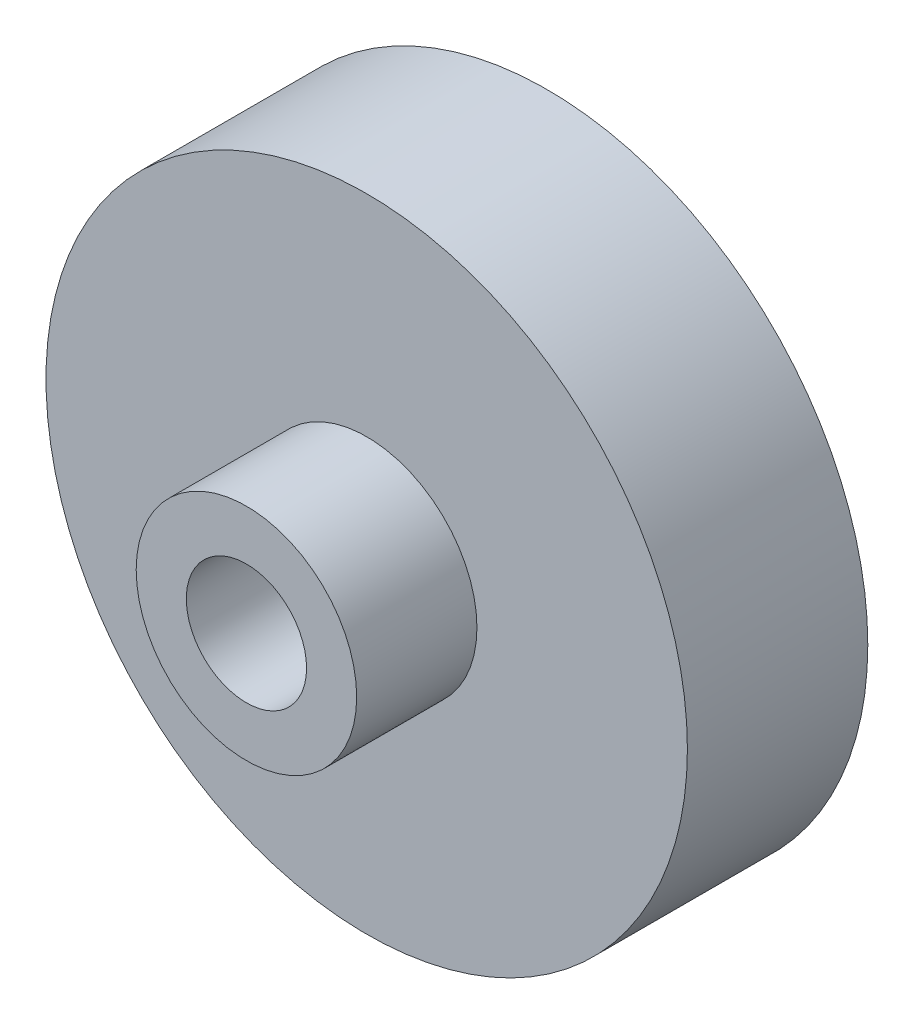
from build123d import *

# Parameters (mm, degrees)
SKETCH_1_R          = 16
EXTRUDE_1_DEPTH     = 9
SKETCH_2_R          = 6
EXTRUDE_2_DEPTH     = 0.5
SKETCH_3_R          = 16
EXTRUDE_3_DEPTH     = 3.25
SKETCH_4_R          = 5.5
EXTRUDE_4_DEPTH     = 2.25
SKETCH_5_R          = 3
CUT_EXTRUDE_1_DEPTH = 26.25
SKETCH_6_R          = 8
SKETCH_6_R_2        = 5.5
CUT_EXTRUDE_2_DEPTH = 2.25
SKETCH_7_R          = 0.6
CUT_EXTRUDE_3_DEPTH = 6
SKETCH_8_R          = 0.6
CUT_EXTRUDE_4_DEPTH = 3
SKETCH_9_R          = 18.290801542
SKETCH_9_R_2        = 5.5
CUT_EXTRUDE_5_DEPTH = 3.75


with BuildPart() as part:
    # 草图1 → 凸台-拉伸1 (new body)
    with BuildSketch(Plane.XY):
        Circle(SKETCH_1_R)
    extrude(amount=EXTRUDE_1_DEPTH)

    # 草图2 → 凸台-拉伸2 (add)
    with BuildSketch(Plane.XY.offset(9)):
        Circle(SKETCH_2_R)
    extrude(amount=EXTRUDE_2_DEPTH)

    # 草图3 → 凸台-拉伸3 (add)
    with BuildSketch(Plane.XY.offset(9.5)):
        Circle(SKETCH_3_R)
    extrude(amount=EXTRUDE_3_DEPTH)

    # 草图4 → 凸台-拉伸4 (add)
    with BuildSketch(Plane.XY.offset(12.75)):
        Circle(SKETCH_4_R)
    extrude(amount=EXTRUDE_4_DEPTH)

    # 草图5 → 切除-拉伸1 (cut)
    with BuildSketch(Plane.XY.offset(15)):
        Circle(SKETCH_5_R)
    extrude(amount=-CUT_EXTRUDE_1_DEPTH, mode=Mode.SUBTRACT)

    # 草图6 → 切除-拉伸2 (cut)
    with BuildSketch(Plane.XY.offset(12.75)):
        Circle(SKETCH_6_R)
        Circle(SKETCH_6_R_2, mode=Mode.SUBTRACT)
    extrude(amount=-CUT_EXTRUDE_2_DEPTH, mode=Mode.SUBTRACT)

    # 草图7 → 切除-拉伸3 (cut)
    with BuildSketch(Plane(origin=(0, 0, 0), x_dir=(-1, 0, 0), z_dir=(0, 0, -1))):
        with Locations((8.660254038, 5)):
            Circle(SKETCH_7_R)
        with Locations((-8.660254038, 5)):
            Circle(SKETCH_7_R)
        with Locations((0, -10)):
            Circle(SKETCH_7_R)
    extrude(amount=-CUT_EXTRUDE_3_DEPTH, mode=Mode.SUBTRACT)

    # 草图8 → 切除-拉伸4 (cut)
    with BuildSketch(Plane.XY.offset(12.75)):
        with Locations((5, -8.660254038)):
            Circle(SKETCH_8_R)
        with Locations((5, 8.660254038)):
            Circle(SKETCH_8_R)
        with Locations((-10, 0)):
            Circle(SKETCH_8_R)
    extrude(amount=-CUT_EXTRUDE_4_DEPTH, mode=Mode.SUBTRACT)

    # 草图9 → 切除-拉伸5 (cut)
    with BuildSketch(Plane.XY.offset(12.75)):
        Circle(SKETCH_9_R)
        Circle(SKETCH_9_R_2, mode=Mode.SUBTRACT)
    extrude(amount=-CUT_EXTRUDE_5_DEPTH, mode=Mode.SUBTRACT)


solid = part.part
